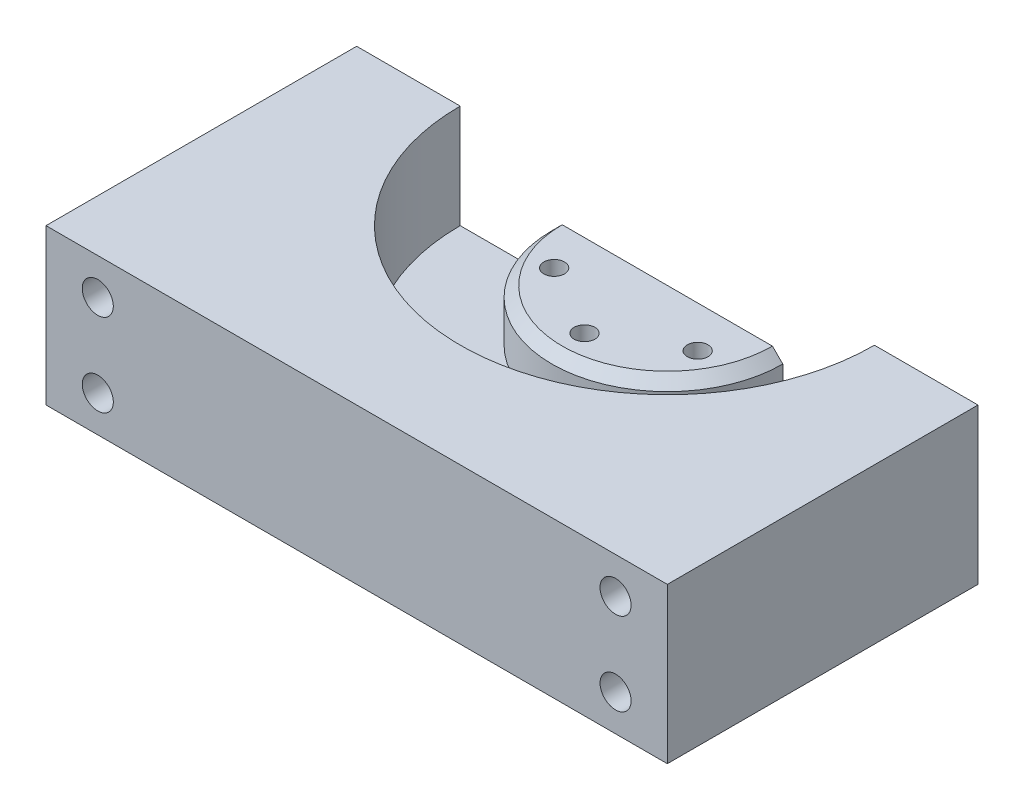
from build123d import *

# Parameters (mm, degrees)
ESQUISSE1_W             = 120
ESQUISSE1_H             = 60
BOSS_EXTRU_1_DEPTH      = 10
BOSS_EXTRU_2_DEPTH      = 20
BOSS_EXTRU_3_DEPTH      = 10
CHANFREIN1_SIZE         = 2
ENL_V_MAT_EXTRU_1_REACH = 62
ESQUISSE4_R             = 3
ENL_V_MAT_EXTRU_2_REACH = 22
ESQUISSE5_R             = 2


with BuildPart() as part:
    # Esquisse1 → Boss.-Extru.1 (new body)
    with BuildSketch(Plane(origin=(0, 0, 0), x_dir=(1, 0, 0), z_dir=(0, 1, 0))):
        Rectangle(ESQUISSE1_W, ESQUISSE1_H)
    extrude(amount=BOSS_EXTRU_1_DEPTH)

    # Esquisse2 → Boss.-Extru.2 (add)
    with BuildSketch(Plane(origin=(0, 10, 0), x_dir=(1, 0, 0), z_dir=(0, 1, 0))):
        with BuildLine():
            Line((-40, 30), (-60, 30))
            Line((-60, 30), (-60, -30))
            Line((-60, -30), (60, -30))
            Line((60, -30), (60, 30))
            Line((60, 30), (40, 30))
            ThreePointArc((40, 30), (0, -10), (-40, 30))
        make_face()
    extrude(amount=BOSS_EXTRU_2_DEPTH)

    # Esquisse3 → Boss.-Extru.3 (add)
    with BuildSketch(Plane(origin=(0, 10, 0), x_dir=(1, 0, 0), z_dir=(0, 1, 0))):
        with BuildLine():
            Line((-22.3, 30), (22.3, 30))
            ThreePointArc((22.3, 30), (0, 7.7), (-22.3, 30))
        make_face()
    extrude(amount=BOSS_EXTRU_3_DEPTH)

    # Chanfrein1
    chanfrein1_edges = [part.edges().sort_by_distance(p)[0] for p in [
        (0, 20, -7.7),
    ]]
    chamfer(chanfrein1_edges, length=CHANFREIN1_SIZE)

    # Esquisse4 → Enlèv. mat.-Extru.1 (cut, up to next)
    with BuildSketch(Plane(origin=(0, 0, -30), x_dir=(-1, 0, 0), z_dir=(0, 0, -1)), mode=Mode.PRIVATE) as enl_v_mat_extru_1_sk1:
        with Locations((-50, 23)):
            Circle(ESQUISSE4_R)
    enl_v_mat_extru_1_tool1 = extrude(enl_v_mat_extru_1_sk1.sketch, amount=-ENL_V_MAT_EXTRU_1_REACH, mode=Mode.PRIVATE) & part.part
    add(enl_v_mat_extru_1_tool1.solids().sort_by_distance((50, 23, -30))[0], mode=Mode.SUBTRACT)
    # Esquisse4 → Enlèv. mat.-Extru.1 (cut, up to next)
    with BuildSketch(Plane(origin=(0, 0, -30), x_dir=(-1, 0, 0), z_dir=(0, 0, -1)), mode=Mode.PRIVATE) as enl_v_mat_extru_1_sk2:
        with Locations((50, 23)):
            Circle(ESQUISSE4_R)
    enl_v_mat_extru_1_tool2 = extrude(enl_v_mat_extru_1_sk2.sketch, amount=-ENL_V_MAT_EXTRU_1_REACH, mode=Mode.PRIVATE) & part.part
    add(enl_v_mat_extru_1_tool2.solids().sort_by_distance((-50, 23, -30))[0], mode=Mode.SUBTRACT)
    # Esquisse4 → Enlèv. mat.-Extru.1 (cut, up to next)
    with BuildSketch(Plane(origin=(0, 0, -30), x_dir=(-1, 0, 0), z_dir=(0, 0, -1)), mode=Mode.PRIVATE) as enl_v_mat_extru_1_sk3:
        with Locations((-50, 7)):
            Circle(ESQUISSE4_R)
    enl_v_mat_extru_1_tool3 = extrude(enl_v_mat_extru_1_sk3.sketch, amount=-ENL_V_MAT_EXTRU_1_REACH, mode=Mode.PRIVATE) & part.part
    add(enl_v_mat_extru_1_tool3.solids().sort_by_distance((50, 7, -30))[0], mode=Mode.SUBTRACT)
    # Esquisse4 → Enlèv. mat.-Extru.1 (cut, up to next)
    with BuildSketch(Plane(origin=(0, 0, -30), x_dir=(-1, 0, 0), z_dir=(0, 0, -1)), mode=Mode.PRIVATE) as enl_v_mat_extru_1_sk4:
        with Locations((50, 7)):
            Circle(ESQUISSE4_R)
    enl_v_mat_extru_1_tool4 = extrude(enl_v_mat_extru_1_sk4.sketch, amount=-ENL_V_MAT_EXTRU_1_REACH, mode=Mode.PRIVATE) & part.part
    add(enl_v_mat_extru_1_tool4.solids().sort_by_distance((-50, 7, -30))[0], mode=Mode.SUBTRACT)

    # Esquisse5 → Enlèv. mat.-Extru.2 (cut, up to next)
    with BuildSketch(Plane(origin=(0, 20, 0), x_dir=(1, 0, 0), z_dir=(0, 1, 0)), mode=Mode.PRIVATE) as enl_v_mat_extru_2_sk1:
        with Locations((0, 14)):
            Circle(ESQUISSE5_R)
    enl_v_mat_extru_2_tool1 = extrude(enl_v_mat_extru_2_sk1.sketch, amount=-ENL_V_MAT_EXTRU_2_REACH, mode=Mode.PRIVATE) & part.part
    add(enl_v_mat_extru_2_tool1.solids().sort_by_distance((0, 20, -14))[0], mode=Mode.SUBTRACT)
    # Esquisse5 → Enlèv. mat.-Extru.2 (cut, up to next)
    with BuildSketch(Plane(origin=(0, 20, 0), x_dir=(1, 0, 0), z_dir=(0, 1, 0)), mode=Mode.PRIVATE) as enl_v_mat_extru_2_sk2:
        with Locations((-13.856406461, 22)):
            Circle(ESQUISSE5_R)
    enl_v_mat_extru_2_tool2 = extrude(enl_v_mat_extru_2_sk2.sketch, amount=-ENL_V_MAT_EXTRU_2_REACH, mode=Mode.PRIVATE) & part.part
    add(enl_v_mat_extru_2_tool2.solids().sort_by_distance((-13.856406, 20, -22))[0], mode=Mode.SUBTRACT)
    # Esquisse5 → Enlèv. mat.-Extru.2 (cut, up to next)
    with BuildSketch(Plane(origin=(0, 20, 0), x_dir=(1, 0, 0), z_dir=(0, 1, 0)), mode=Mode.PRIVATE) as enl_v_mat_extru_2_sk3:
        with Locations((13.856406461, 22)):
            Circle(ESQUISSE5_R)
    enl_v_mat_extru_2_tool3 = extrude(enl_v_mat_extru_2_sk3.sketch, amount=-ENL_V_MAT_EXTRU_2_REACH, mode=Mode.PRIVATE) & part.part
    add(enl_v_mat_extru_2_tool3.solids().sort_by_distance((13.856406, 20, -22))[0], mode=Mode.SUBTRACT)


solid = part.part
